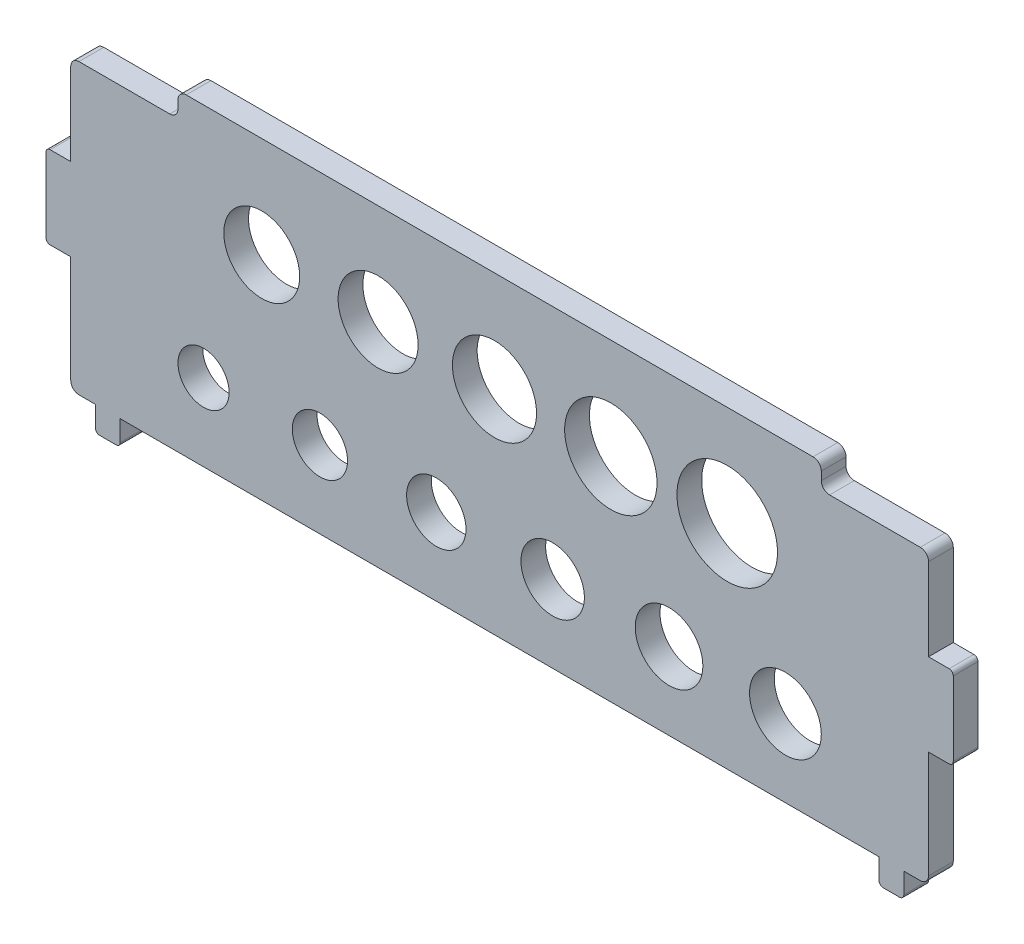
from build123d import *

# Parameters (mm, degrees)
SKETCH_1_R      = 3.1
SKETCH_1_R_2    = 3.35
SKETCH_1_R_3    = 3.6
SKETCH_1_R_4    = 3.85
SKETCH_1_R_5    = 4.1
SKETCH_1_R_6    = 4.35
SKETCH_1_R_7    = 4.6
SKETCH_1_R_8    = 4.85
SKETCH_1_R_9    = 5.1
SKETCH_1_R_10   = 5.6
SKETCH_1_R_11   = 6.1
SKETCH_1_W      = 3
SKETCH_1_H      = 10
EXTRUDE_1_DEPTH = 3
FILLET_1_R      = 0.5
FILLET_2_R      = 1


with BuildPart() as part:
    # Эскиз1 → Бобышка-Вытянуть1 (new body)
    with BuildSketch(Plane.XY):
        Polygon((39, 19), (-39, 19), (-39, 16), (-52, 16), (-52, 5), (-52, -5), (-52, -19), (-49, -19), (-49, -22), (-46, -22), (-46, -19), (0, -19), (46, -19), (46, -22), (49, -22), (49, -19), (52, -19), (52, -5), (52, 5), (52, 16), (39, 16), align=None)
        with Locations((-35.9, -9.65)):
            Circle(SKETCH_1_R, mode=Mode.SUBTRACT)
        with Locations((-21.79, -9.65)):
            Circle(SKETCH_1_R_2, mode=Mode.SUBTRACT)
        with Locations((-7.68, -9.65)):
            Circle(SKETCH_1_R_3, mode=Mode.SUBTRACT)
        with Locations((6.43, -9.65)):
            Circle(SKETCH_1_R_4, mode=Mode.SUBTRACT)
        with Locations((20.54, -9.65)):
            Circle(SKETCH_1_R_5, mode=Mode.SUBTRACT)
        with Locations((34.65, -9.65)):
            Circle(SKETCH_1_R_6, mode=Mode.SUBTRACT)
        with Locations((-28.845, 6.8)):
            Circle(SKETCH_1_R_7, mode=Mode.SUBTRACT)
        with Locations((-14.735, 6.8)):
            Circle(SKETCH_1_R_8, mode=Mode.SUBTRACT)
        with Locations((-0.625, 6.8)):
            Circle(SKETCH_1_R_9, mode=Mode.SUBTRACT)
        with Locations((13.485, 6.8)):
            Circle(SKETCH_1_R_10, mode=Mode.SUBTRACT)
        with Locations((27.595, 6.8)):
            Circle(SKETCH_1_R_11, mode=Mode.SUBTRACT)
        with Locations((-53.5, 0)):
            Rectangle(SKETCH_1_W, SKETCH_1_H)
        with Locations((53.5, 0)):
            Rectangle(SKETCH_1_W, SKETCH_1_H)
    extrude(amount=EXTRUDE_1_DEPTH)

    # Скругление1
    fillet_1_edges = [part.edges().sort_by_distance(p)[0] for p in [
        (-55, -5, 1.5),
        (-55, 5, 1.5),
        (55, 5, 1.5),
        (55, -5, 1.5),
        (49, -22, 1.5),
        (46, -22, 1.5),
        (-46, -22, 1.5),
        (-49, -22, 1.5),
    ]]
    fillet(fillet_1_edges, radius=FILLET_1_R)

    # Скругление2
    fillet_2_edges = [part.edges().sort_by_distance(p)[0] for p in [
        (-52, -19, 1.5),
        (-52, 16, 1.5),
        (-39, 16, 1.5),
        (-39, 19, 1.5),
        (39, 19, 1.5),
        (39, 16, 1.5),
        (52, 16, 1.5),
        (52, -19, 1.5),
    ]]
    fillet(fillet_2_edges, radius=FILLET_2_R)


solid = part.part
